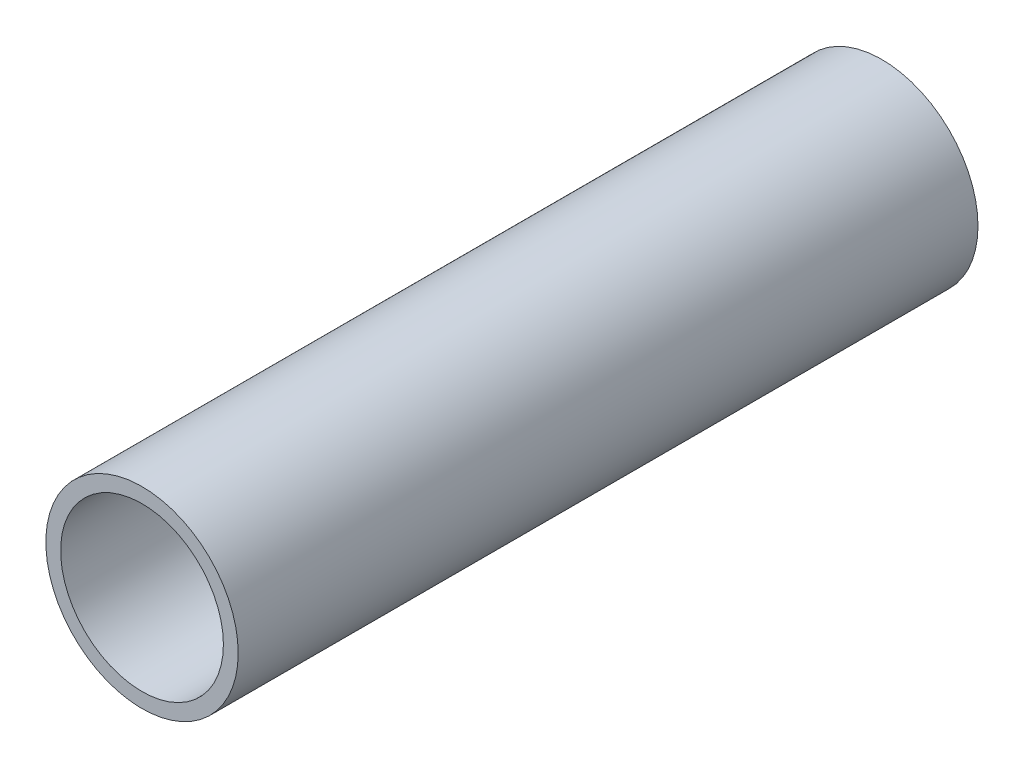
from build123d import *

# Parameters (mm, degrees)
SKETCH_1_R      = 65
SKETCH_1_R_2    = 55
EXTRUDE_1_DEPTH = 500


with BuildPart() as part:
    # Эскиз1 → Бобышка-Вытянуть1 (new body)
    with BuildSketch(Plane.XY):
        Circle(SKETCH_1_R)
        Circle(SKETCH_1_R_2, mode=Mode.SUBTRACT)
    extrude(amount=EXTRUDE_1_DEPTH)


solid = part.part
